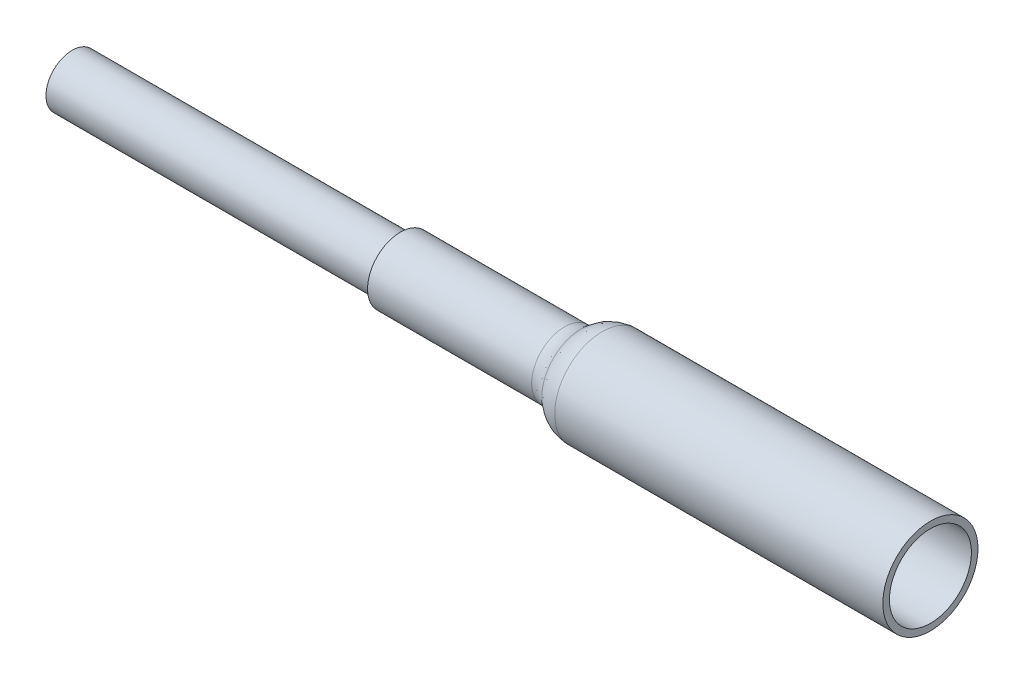
from build123d import *


with BuildPart() as part:
    # Sketch1 → Revolve1 (revolve)
    with BuildSketch(Plane(origin=(0, 0, 0), x_dir=(1, 0, 0), z_dir=(0, 1, 0))):
        with BuildLine():
            Line((0, 0), (0, 1.016))
            Line((0, 1.016), (12.7, 1.016))
            Line((12.7, 1.016), (12.7, 1.27))
            Line((12.7, 1.27), (19.05, 1.27))
            ThreePointArc((19.05, 1.27), (19.396522774, 1.335269355), (19.695555117, 1.522132353))
            ThreePointArc((19.695555117, 1.522132353), (20.074329418, 1.758825483), (20.513258265, 1.8415))
            Line((20.513258265, 1.8415), (33.213258265, 1.8415))
            Line((33.213258265, 1.8415), (33.213258265, 1.5875))
            Line((33.213258265, 1.5875), (20.513258265, 1.5875))
            ThreePointArc((20.513258265, 1.5875), (20.166735491, 1.522230645), (19.867703148, 1.335367647))
            ThreePointArc((19.867703148, 1.335367647), (19.488928847, 1.098674517), (19.05, 1.016))
            Line((19.05, 1.016), (20.513258265, 1.016))
            Line((20.513258265, 1.016), (20.513258265, 0.635))
            Line((20.513258265, 0.635), (25.593258265, 0.635))
            Line((25.593258265, 0.635), (25.593258265, 0))
            Line((25.593258265, 0), (0, 0))
        make_face()
    revolve(axis=Axis((25.593258265, 0, 0), (-1, 0, 0)))


solid = part.part
